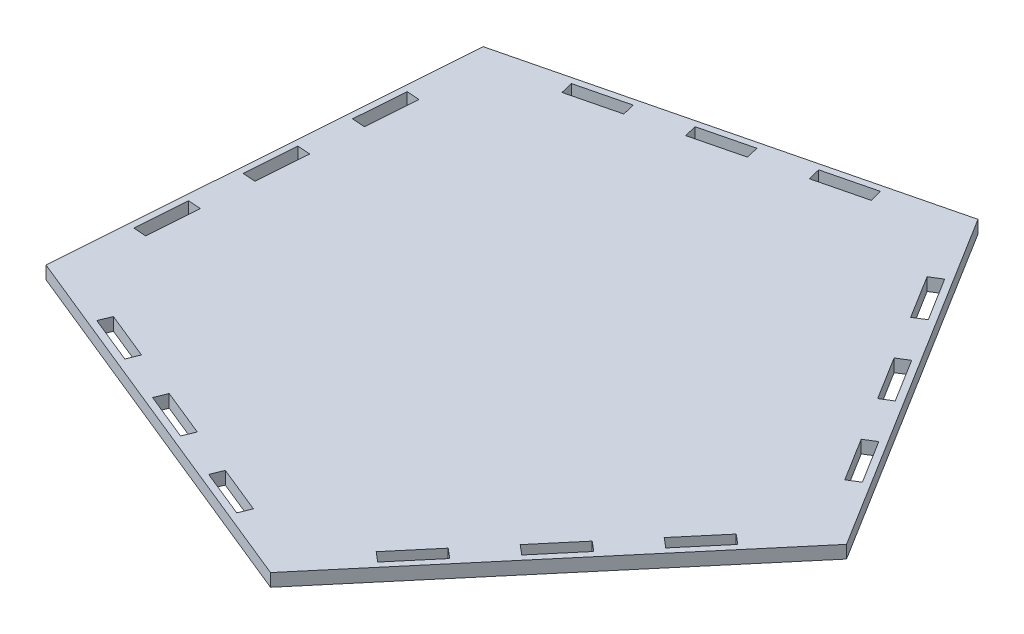
from build123d import *

# Parameters (mm, degrees)
BOSS_EXTRUDE1_DEPTH = 6.35
CUT_EXTRUDE1_DEPTH  = 7.35
CUT_EXTRUDE2_DEPTH  = 7.35
CUT_EXTRUDE3_DEPTH  = 7.35
CUT_EXTRUDE4_DEPTH  = 7.35
CUT_EXTRUDE5_DEPTH  = 7.35


with BuildPart() as part:
    # Sketch1 → Boss-Extrude1 (new body)
    with BuildSketch(Plane(origin=(0, 0, 0), x_dir=(1, 0, 0), z_dir=(0, 1, 0))):
        Polygon((-472.762098838, -38.601599313), (-579.996957803, 133.998878735), (-777.287160977, 85.348948297), (-791.984353221, -117.318840313), (-603.777514393, -193.924491661), align=None)
    extrude(amount=BOSS_EXTRUDE1_DEPTH)

    # Sketch2 → Cut-Extrude1 (cut, through all)
    with BuildSketch(Plane(origin=(0, 6.35, 0), x_dir=(1, 0, 0), z_dir=(0, 1, 0))):
        Polygon((-659.001261619, -161.163030045), (-635.475406766, -170.738736463), (-637.86933337, -176.620200176), (-661.395188224, -167.044493758), align=None)
        Polygon((-706.052971326, -142.011617208), (-682.527116473, -151.587323626), (-684.921043077, -157.46878734), (-708.446897931, -147.893080921), align=None)
        Polygon((-753.053854552, -122.735332494), (-729.527999698, -132.311038913), (-731.921926303, -138.192502626), (-755.447781156, -128.616796208), align=None)
    extrude(amount=-CUT_EXTRUDE1_DEPTH, mode=Mode.SUBTRACT)

    # Sketch4 → Cut-Extrude2 (cut, through all)
    with BuildSketch(Plane(origin=(0, 6.35, 0), x_dir=(1, 0, 0), z_dir=(0, 1, 0))):
        Polygon((-570.115957611, -139.244740198), (-565.262117225, -143.338971934), (-581.639044169, -162.754333478), (-586.492884555, -158.660101741), align=None)
        Polygon((-520.985176778, -80.998655568), (-516.131336392, -85.092887304), (-499.754409447, -65.677525761), (-504.608249833, -61.583294024), align=None)
        Polygon((-548.88519028, -123.923610391), (-532.508263336, -104.508248847), (-537.362103722, -100.414017111), (-553.739030666, -119.829378655), align=None)
    extrude(amount=-CUT_EXTRUDE2_DEPTH, mode=Mode.SUBTRACT)

    # Sketch5 → Cut-Extrude3 (cut, through all)
    with BuildSketch(Plane(origin=(0, 6.35, 0), x_dir=(1, 0, 0), z_dir=(0, 1, 0))):
        Polygon((-777.891428053, -54.674087259), (-784.224796447, -54.214800001), (-786.061945478, -79.548273578), (-779.728577084, -80.007560835), align=None)
        Polygon((-774.217129992, -4.007140106), (-780.550498387, -3.547852849), (-782.387647417, -28.881326425), (-776.054279023, -29.340613683), align=None)
        Polygon((-776.876200326, 47.119094304), (-770.542831932, 46.659807046), (-772.379980962, 21.32633347), (-778.713349356, 21.785620727), align=None)
    extrude(amount=-CUT_EXTRUDE3_DEPTH, mode=Mode.SUBTRACT)

    # Sketch6 → Cut-Extrude4 (cut, through all)
    with BuildSketch(Plane(origin=(0, 6.35, 0), x_dir=(1, 0, 0), z_dir=(0, 1, 0))):
        Polygon((-508.969874734, 13.660505405), (-495.565517364, -7.914554351), (-500.959282303, -11.265643693), (-514.363639673, 10.309416063), align=None)
        Polygon((-522.374232105, 35.235565162), (-527.767997044, 31.884475819), (-541.172354415, 53.459535575), (-535.778589476, 56.810624918), align=None)
        Polygon((-549.139796727, 78.412493389), (-554.533561666, 75.061404046), (-567.937919036, 96.636463802), (-562.544154097, 99.987553145), align=None)
    extrude(amount=-CUT_EXTRUDE4_DEPTH, mode=Mode.SUBTRACT)

    # Sketch7 → Cut-Extrude5 (cut, through all)
    with BuildSketch(Plane(origin=(0, 6.35, 0), x_dir=(1, 0, 0), z_dir=(0, 1, 0))):
        Polygon((-614.708405409, 115.629038504), (-639.369680806, 109.5477972), (-640.889991132, 115.713116049), (-616.228715735, 121.794357354), align=None)
        Polygon((-665.551266529, 109.631874744), (-690.212541925, 103.550633439), (-688.692231599, 97.38531459), (-664.030956203, 103.466555895), align=None)
        Polygon((-714.873817322, 97.469392134), (-739.535092719, 91.38815083), (-738.014782393, 85.22283198), (-713.353506996, 91.304073285), align=None)
    extrude(amount=-CUT_EXTRUDE5_DEPTH, mode=Mode.SUBTRACT)


solid = part.part
